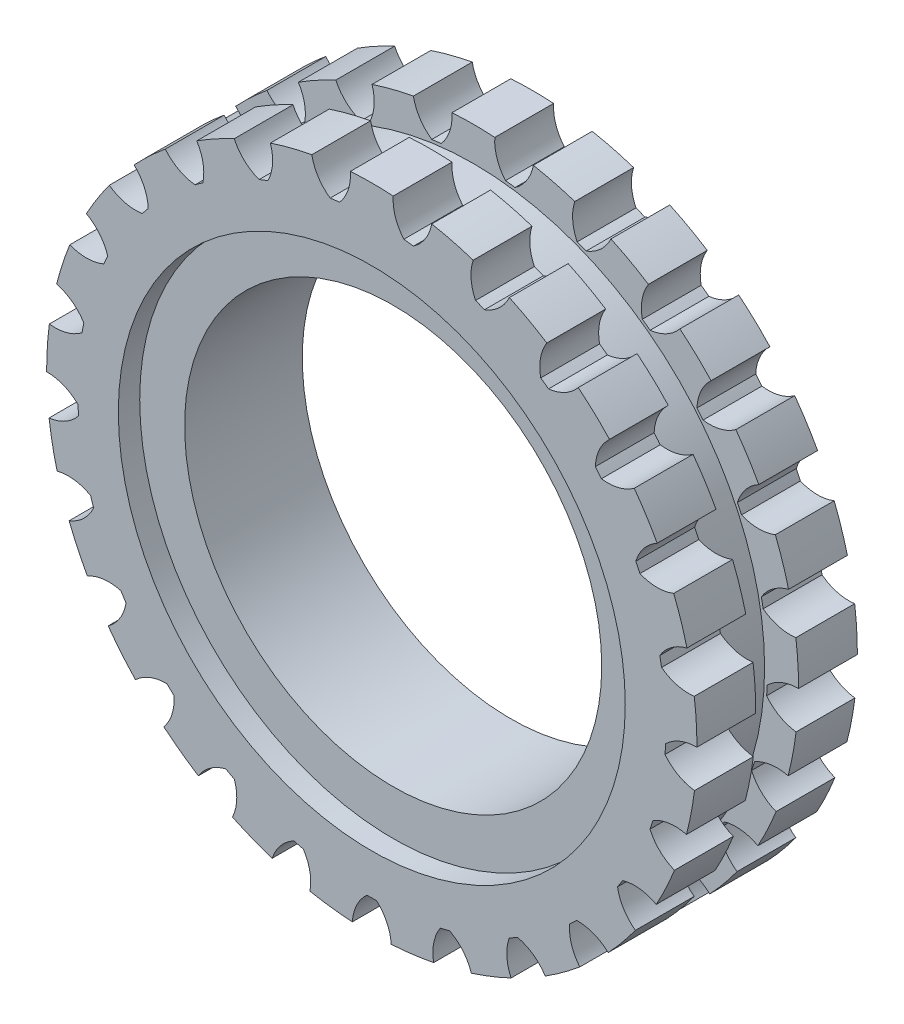
from build123d import *

# Parameters (mm, degrees)
AUFSATZ_LINEAR_AUSTRAGEN1_DEPTH = 15
SKIZZE3_W                       = 4
SKIZZE3_H                       = 3.612737083


with BuildPart() as part:
    # Skizze1 → Rotation1 (revolve)
    with BuildSketch(Plane(origin=(0, 0, 0), x_dir=(0, 0, -1), z_dir=(1, 0, 0))):
        Polygon((-5.5, 0), (5.5, 0), (5.5, 4.2), (7.5, 4.2), (7.5, 8), (-7.5, 8), (-7.5, 4.2), (-5.5, 4.2), align=None)
    revolve(axis=Axis((0, -19.5, 17.330416941), (0, 0, -1)))

    # Skizze2 → Aufsatz-Linear austragen1 (add, through all)
    with BuildSketch(Plane.XY.offset(7.5)):
        with BuildLine():
            ThreePointArc((-3, 7.835873866), (0, 8), (3, 7.835873866))
            ThreePointArc((3, 7.835873866), (2.205617665, 9.237746421), (2, 10.835873866))
            ThreePointArc((2, 10.835873866), (0, 10.901730924), (-2, 10.835873866))
            ThreePointArc((-2, 10.835873866), (-2.205617665, 9.237746421), (-3, 7.835873866))
        make_face()
        with BuildLine():
            ThreePointArc((5.607058726, 10.380196379), (7.560603033, 9.946604642), (9.481391371, 9.38543683))
            ThreePointArc((9.481391371, 9.38543683), (9.283111045, 7.786382464), (9.703904871, 6.23099746))
            ThreePointArc((9.703904871, 6.23099746), (6.838971897, 7.136036931), (3.892405904, 7.723136783))
            ThreePointArc((3.892405904, 7.723136783), (5.010462785, 8.88341208), (5.607058726, 10.380196379))
        make_face()
        with BuildLine():
            ThreePointArc((12.861805332, 8.047036262), (14.646145572, 7.141239894), (16.367032052, 6.120021565))
            ThreePointArc((16.367032052, 6.120021565), (15.777312417, 4.620514744), (15.79807771, 3.009347851))
            ThreePointArc((15.79807771, 3.009347851), (13.248226038, 4.598433701), (10.540237629, 5.899869896))
            ThreePointArc((10.540237629, 5.899869896), (11.91171743, 6.745643571), (12.861805332, 8.047036262))
        make_face()
        with BuildLine():
            ThreePointArc((19.308397406, 3.982994545), (20.811416919, 2.661908063), (22.224271915, 1.244806122))
            ThreePointArc((22.224271915, 1.244806122), (21.280167225, -0.060933626), (20.899599225, -1.626646867))
            ThreePointArc((20.899599225, -1.626646867), (18.825045413, 0.546637254), (16.525787461, 2.480635769))
            ThreePointArc((16.525787461, 2.480635769), (18.064515061, 2.958764753), (19.308397406, 3.982994545))
        make_face()
        with BuildLine():
            ThreePointArc((24.541771859, -1.556570083), (25.669030403, -3.209937957), (26.685079039, -4.933881785))
            ThreePointArc((26.685079039, -4.933881785), (25.445910863, -5.963810028), (24.687922058, -7.385690095))
            ThreePointArc((24.687922058, -7.385690095), (23.219017951, -4.764763138), (21.472961288, -2.319722542))
            ThreePointArc((21.472961288, -2.319722542), (23.082252775, -2.239280853), (24.541771859, -1.556570083))
        make_face()
        with BuildLine():
            ThreePointArc((28.233096529, -8.223586404), (28.913764302, -10.105348486), (29.469164506, -12.027812469))
            ThreePointArc((29.469164506, -12.027812469), (28.012794338, -12.717215028), (26.925011952, -13.905919968))
            ThreePointArc((26.925011952, -13.905919968), (26.154054198, -11.002032655), (25.070909985, -8.199580871))
            ThreePointArc((25.070909985, -8.199580871), (26.649647655, -8.521880924), (28.233096529, -8.223586404))
        make_face()
        with BuildLine():
            ThreePointArc((30.150431909, -15.599141263), (30.341740053, -17.591059521), (30.401593987, -19.591248176))
            ThreePointArc((30.401593987, -19.591248176), (28.819530922, -19.896807354), (27.470304321, -20.777646463))
            ThreePointArc((27.470304321, -20.777646463), (27.445735032, -17.773260713), (27.093561204, -14.789486093))
            ThreePointArc((27.093561204, -14.789486093), (28.542547163, -15.49427659), (30.150431909, -15.599141263))
        make_face()
        with BuildLine():
            ThreePointArc((30.173304767, -23.219801423), (29.863232687, -25.196716306), (29.423779509, -27.148950426))
            ThreePointArc((29.423779509, -27.148950426), (27.815430386, -27.051466815), (26.289536442, -27.569093732))
            ThreePointArc((26.289536442, -27.569093732), (27.012899395, -24.652986151), (27.41382433, -21.675370228))
            ThreePointArc((27.41382433, -21.675370228), (28.642013461, -22.71836659), (30.173304767, -23.219801423))
        make_face()
        with BuildLine():
            ThreePointArc((28.300277917, -30.606732779), (27.508308582, -32.444427455), (26.597160751, -34.226040988))
            ThreePointArc((26.597160751, -34.226040988), (25.063584062, -33.731639843), (23.456900302, -33.853530166))
            ThreePointArc((23.456900302, -33.853530166), (24.882743943, -31.208930518), (26.011576051, -28.424567851))
            ThreePointArc((26.011576051, -28.424567851), (26.941796715, -29.740234782), (28.300277917, -30.606732779))
        make_face()
        with BuildLine():
            ThreePointArc((24.649040524, -37.295787266), (23.42493628, -38.878792621), (22.099344565, -40.377840238))
            ThreePointArc((22.099344565, -40.377840238), (20.736900573, -39.517586599), (19.150380847, -39.236081511))
            ThreePointArc((19.150380847, -39.236081511), (21.189114176, -37.029159718), (22.974924786, -34.613002054))
            ThreePointArc((22.974924786, -34.613002054), (23.548727796, -36.118671361), (24.649040524, -37.295787266))
        make_face()
        with BuildLine():
            ThreePointArc((19.449013262, -42.866666992), (17.869689081, -44.095516976), (16.212945285, -45.217808001))
            ThreePointArc((16.212945285, -45.217808001), (15.107241356, -44.04575477), (13.640572534, -43.37854227))
            ThreePointArc((13.640572534, -43.37854227), (16.164094438, -41.747967345), (18.4946745, -39.851830757))
            ThreePointArc((18.4946745, -39.851830757), (18.676005704, -41.452895699), (19.449013262, -42.866666992))
        make_face()
        with BuildLine():
            ThreePointArc((13.026932969, -46.969333094), (11.191623597, -47.766814544), (9.307827025, -48.441831305))
            ThreePointArc((9.307827025, -48.441831305), (8.528338605, -47.031622895), (7.273676881, -46.0206264))
            ThreePointArc((7.273676881, -46.0206264), (10.123425199, -45.068853362), (12.852335797, -43.811879083))
            ThreePointArc((12.852335797, -43.811879083), (12.629801488, -45.407738863), (13.026932969, -46.969333094))
        make_face()
        with BuildLine():
            ThreePointArc((5.786322567, -49.345999972), (3.810347243, -49.662004195), (1.817863762, -49.847332906))
            ThreePointArc((1.817863762, -49.847332906), (1.413568974, -48.2875779), (0.44974936, -46.996322036))
            ThreePointArc((0.44974936, -46.996322036), (3.446663923, -46.783154286), (6.402437568, -46.244322635))
            ThreePointArc((6.402437568, -46.244322635), (5.790020395, -47.734703513), (5.786322567, -49.345999972))
        make_face()
        with BuildLine():
            ThreePointArc((-1.817863762, -49.847332906), (-3.810347243, -49.662004195), (-5.786322567, -49.345999972))
            ThreePointArc((-5.786322567, -49.345999972), (-5.790020395, -47.734703513), (-6.402437568, -46.244322635))
            ThreePointArc((-6.402437568, -46.244322635), (-3.446663923, -46.783154286), (-0.44974936, -46.996322036))
            ThreePointArc((-0.44974936, -46.996322036), (-1.413568974, -48.2875779), (-1.817863762, -49.847332906))
        make_face()
        with BuildLine():
            ThreePointArc((-9.307827025, -48.441831305), (-11.191623597, -47.766814544), (-13.026932969, -46.969333094))
            ThreePointArc((-13.026932969, -46.969333094), (-12.629801488, -45.407738863), (-12.852335797, -43.811879083))
            ThreePointArc((-12.852335797, -43.811879083), (-10.123425199, -45.068853362), (-7.273676881, -46.0206264))
            ThreePointArc((-7.273676881, -46.0206264), (-8.528338605, -47.031622895), (-9.307827025, -48.441831305))
        make_face()
        with BuildLine():
            ThreePointArc((-16.212945285, -45.217808001), (-17.869689081, -44.095516976), (-19.449013262, -42.866666992))
            ThreePointArc((-19.449013262, -42.866666992), (-18.676005704, -41.452895699), (-18.4946745, -39.851830757))
            ThreePointArc((-18.4946745, -39.851830757), (-16.164094438, -41.747967345), (-13.640572534, -43.37854227))
            ThreePointArc((-13.640572534, -43.37854227), (-15.107241356, -44.04575477), (-16.212945285, -45.217808001))
        make_face()
        with BuildLine():
            ThreePointArc((-22.099344565, -40.377840238), (-23.42493628, -38.878792621), (-24.649040524, -37.295787266))
            ThreePointArc((-24.649040524, -37.295787266), (-23.548727796, -36.118671361), (-22.974924786, -34.613002054))
            ThreePointArc((-22.974924786, -34.613002054), (-21.189114176, -37.029159718), (-19.150380847, -39.236081511))
            ThreePointArc((-19.150380847, -39.236081511), (-20.736900573, -39.517586599), (-22.099344565, -40.377840238))
        make_face()
        with BuildLine():
            ThreePointArc((-26.597160751, -34.226040988), (-27.508308582, -32.444427455), (-28.300277917, -30.606732779))
            ThreePointArc((-28.300277917, -30.606732779), (-26.941796715, -29.740234782), (-26.011576051, -28.424567851))
            ThreePointArc((-26.011576051, -28.424567851), (-24.882743943, -31.208930518), (-23.456900302, -33.853530166))
            ThreePointArc((-23.456900302, -33.853530166), (-25.063584062, -33.731639843), (-26.597160751, -34.226040988))
        make_face()
        with BuildLine():
            ThreePointArc((-29.423779509, -27.148950426), (-29.863232687, -25.196716306), (-30.173304767, -23.219801423))
            ThreePointArc((-30.173304767, -23.219801423), (-28.642013461, -22.71836659), (-27.41382433, -21.675370228))
            ThreePointArc((-27.41382433, -21.675370228), (-27.012899395, -24.652986151), (-26.289536442, -27.569093732))
            ThreePointArc((-26.289536442, -27.569093732), (-27.815430386, -27.051466815), (-29.423779509, -27.148950426))
        make_face()
        with BuildLine():
            ThreePointArc((-30.401593987, -19.591248176), (-30.341740053, -17.591059521), (-30.150431909, -15.599141263))
            ThreePointArc((-30.150431909, -15.599141263), (-28.542547163, -15.49427659), (-27.093561204, -14.789486093))
            ThreePointArc((-27.093561204, -14.789486093), (-27.445735032, -17.773260713), (-27.470304321, -20.777646463))
            ThreePointArc((-27.470304321, -20.777646463), (-28.819530922, -19.896807354), (-30.401593987, -19.591248176))
        make_face()
        with BuildLine():
            ThreePointArc((-29.469164506, -12.027812469), (-28.913764302, -10.105348486), (-28.233096529, -8.223586404))
            ThreePointArc((-28.233096529, -8.223586404), (-26.649647655, -8.521880924), (-25.070909985, -8.199580871))
            ThreePointArc((-25.070909985, -8.199580871), (-26.154054198, -11.002032655), (-26.925011952, -13.905919968))
            ThreePointArc((-26.925011952, -13.905919968), (-28.012794338, -12.717215028), (-29.469164506, -12.027812469))
        make_face()
        with BuildLine():
            ThreePointArc((-26.685079039, -4.933881785), (-25.669030403, -3.209937957), (-24.541771859, -1.556570083))
            ThreePointArc((-24.541771859, -1.556570083), (-23.082252775, -2.239280853), (-21.472961288, -2.319722542))
            ThreePointArc((-21.472961288, -2.319722542), (-23.219017951, -4.764763138), (-24.687922058, -7.385690095))
            ThreePointArc((-24.687922058, -7.385690095), (-25.445910863, -5.963810028), (-26.685079039, -4.933881785))
        make_face()
        with BuildLine():
            ThreePointArc((-22.224271915, 1.244806122), (-20.811416919, 2.661908063), (-19.308397406, 3.982994545))
            ThreePointArc((-19.308397406, 3.982994545), (-18.064515061, 2.958764753), (-16.525787461, 2.480635769))
            ThreePointArc((-16.525787461, 2.480635769), (-18.825045413, 0.546637254), (-20.899599225, -1.626646867))
            ThreePointArc((-20.899599225, -1.626646867), (-21.280167225, -0.060933626), (-22.224271915, 1.244806122))
        make_face()
        with BuildLine():
            ThreePointArc((-16.367032052, 6.120021565), (-14.646145572, 7.141239894), (-12.861805332, 8.047036262))
            ThreePointArc((-12.861805332, 8.047036262), (-11.91171743, 6.745643571), (-10.540237629, 5.899869896))
            ThreePointArc((-10.540237629, 5.899869896), (-13.248226038, 4.598433701), (-15.79807771, 3.009347851))
            ThreePointArc((-15.79807771, 3.009347851), (-15.777312417, 4.620514744), (-16.367032052, 6.120021565))
        make_face()
        with BuildLine():
            ThreePointArc((-9.481391371, 9.38543683), (-7.560603033, 9.946604642), (-5.607058726, 10.380196379))
            ThreePointArc((-5.607058726, 10.380196379), (-5.010462785, 8.88341208), (-3.892405904, 7.723136783))
            ThreePointArc((-3.892405904, 7.723136783), (-6.838971897, 7.136036931), (-9.703904871, 6.23099746))
            ThreePointArc((-9.703904871, 6.23099746), (-9.283111045, 7.786382464), (-9.481391371, 9.38543683))
        make_face()
    extrude(amount=-AUFSATZ_LINEAR_AUSTRAGEN1_DEPTH)

    # Skizze3 → Schnitt-Rotation2 (revolve, cut)
    with BuildSketch(Plane(origin=(0, 0, 0), x_dir=(0, 0, -1), z_dir=(1, 0, 0))):
        with Locations((0, 9.529505325)):
            Rectangle(SKIZZE3_W, SKIZZE3_H)
    revolve(axis=Axis((0, -19.50572952, 15.256951875), (0, 0, -1)), mode=Mode.SUBTRACT)


solid = part.part
